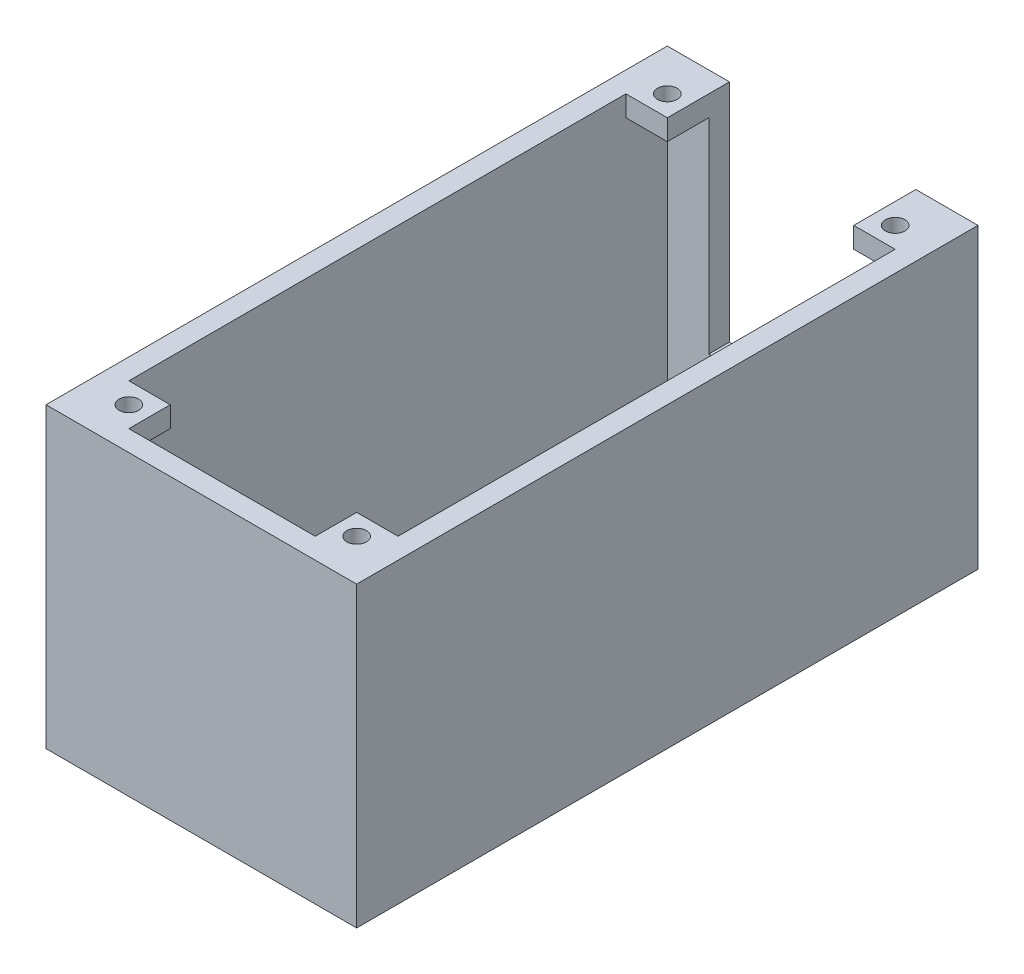
from build123d import *

# Parameters (mm, degrees)
SKETCH1_W                     = 38.1
SKETCH1_H                     = 76.2
BOSS_EXTRUDE1_DEPTH           = 2.54
M2_CLEARANCE_HOLE1_TO_DRONE_D = 2.4
M2_CLEARANCE_HOLE2_TO_PI_D    = 2.4
BOSS_EXTRUDE2_DEPTH           = 33.9852
SKETCH9_R                     = 1.50114
BOSS_EXTRUDE4_DEPTH           = 2.54
SKETCH11_W                    = 33.02
SKETCH11_H                    = 6.096
SKETCH11_R                    = 1.016
BOSS_EXTRUDE6_DEPTH           = 2.54
SKETCH12_W                    = 5.08
SKETCH12_H                    = 5.08
BOSS_EXTRUDE7_DEPTH           = 2.54
M2_CLEARANCE_HOLE1_D          = 2.4
M2_CLEARANCE_HOLE1_DEPTH      = 2.54
M2_CLEARANCE_HOLE1_TIP        = 0.721032743


with BuildPart() as part:
    # Sketch1 → Boss-Extrude1 (new body)
    with BuildSketch(Plane(origin=(0, 0, 0), x_dir=(1, 0, 0), z_dir=(0, 1, 0))):
        Rectangle(SKETCH1_W, SKETCH1_H)
    extrude(amount=BOSS_EXTRUDE1_DEPTH)

    # M2 Clearance Hole1 - to drone (through all)
    with Locations(Plane(origin=(0, 2.54, 0), x_dir=(1, 0, 0), z_dir=(0, 1, 0))):
        with Locations((-13.97, 0), (13.97, 0)):
            Hole(M2_CLEARANCE_HOLE1_TO_DRONE_D / 2)

    # M2 Clearance Hole2 - to Pi (through all)
    with Locations(Plane(origin=(0, 2.54, 0), x_dir=(1, 0, 0), z_dir=(0, 1, 0))):
        with Locations((-5.69976, 23.50008), (5.69976, 23.50008), (5.69976, -23.50008), (-5.69976, -23.50008)):
            Hole(M2_CLEARANCE_HOLE2_TO_PI_D / 2)

    # Sketch7 → Boss-Extrude2 (add)
    with BuildSketch(Plane(origin=(0, 2.54, 0), x_dir=(1, 0, 0), z_dir=(0, 1, 0))):
        Polygon((-19.05, -38.1), (-19.05, -35.56), (-19.05, 38.1), (-16.51, 38.1), (-16.51, -35.56), (16.51, -35.56), (16.51, 38.1), (19.05, 38.1), (19.05, -38.1), align=None)
    extrude(amount=BOSS_EXTRUDE2_DEPTH)

    # Sketch11 → Boss-Extrude6 (add)
    with BuildSketch(Plane(origin=(0, 19.5326, 0), x_dir=(1, 0, 0), z_dir=(0, 1, 0))):
        with Locations((0, -32.512)):
            Rectangle(SKETCH11_W, SKETCH11_H)
        with Locations((-6.985, -31.75)):
            Circle(SKETCH11_R, mode=Mode.SUBTRACT)
        with Locations((6.985, -31.75)):
            Circle(SKETCH11_R, mode=Mode.SUBTRACT)
    extrude(amount=-BOSS_EXTRUDE6_DEPTH)



with BuildPart() as body_2:
    # Sketch9 → Boss-Extrude4 (new body)
    with BuildSketch(Plane(origin=(0, 0, -38.1), x_dir=(-1, 0, 0), z_dir=(0, 0, -1))):
        Polygon((-11.43, 8.89), (11.43, 8.89), (11.43, 36.5252), (16.51, 36.5252), (16.51, 2.54), (-16.51, 2.54), (-16.51, 36.5252), (-11.43, 36.5252), align=None)
        with Locations((-10.31494, 5.715)):
            Circle(SKETCH9_R, mode=Mode.SUBTRACT)
        with Locations((10.31494, 5.715)):
            Circle(SKETCH9_R, mode=Mode.SUBTRACT)
    extrude(amount=-BOSS_EXTRUDE4_DEPTH)


with BuildPart() as part_1:
    add(part.part)

    add(body_2.part)  # Boss-Extrude7 merges body 2
    # Sketch12 → Boss-Extrude7 (add)
    with BuildSketch(Plane(origin=(0, 36.5252, 0), x_dir=(1, 0, 0), z_dir=(0, 1, 0))):
        with Locations((-13.97, -33.02)):
            Rectangle(SKETCH12_W, SKETCH12_H)
        with Locations((13.97, -33.02)):
            Rectangle(SKETCH12_W, SKETCH12_H)
        with Locations((13.97, 33.02)):
            Rectangle(SKETCH12_W, SKETCH12_H)
        with Locations((-13.97, 33.02)):
            Rectangle(SKETCH12_W, SKETCH12_H)
    extrude(amount=-BOSS_EXTRUDE7_DEPTH)

    # M2 Clearance Hole1
    with Locations(Plane(origin=(0, 36.5252, 0), x_dir=(1, 0, 0), z_dir=(0, 1, 0))):
        with Locations((-13.97, 33.02), (13.97, 33.02), (13.97, -33.02), (-13.97, -33.02)):
            Hole(M2_CLEARANCE_HOLE1_D / 2, depth=M2_CLEARANCE_HOLE1_DEPTH)
            with Locations((0, 0, -(M2_CLEARANCE_HOLE1_DEPTH + M2_CLEARANCE_HOLE1_TIP / 2))):  # 118° drill point
                Cone(0, M2_CLEARANCE_HOLE1_D / 2, M2_CLEARANCE_HOLE1_TIP, mode=Mode.SUBTRACT)


solid = part_1.part
